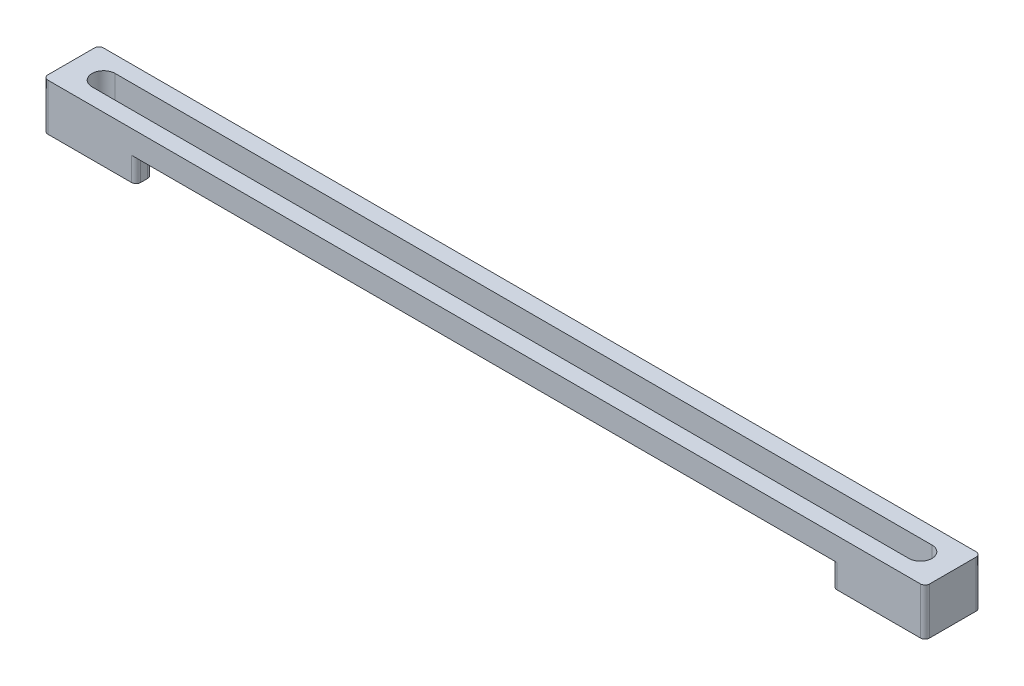
from build123d import *

# Parameters (mm, degrees)
ESQUISSE1_W        = 190
ESQUISSE1_H        = 12
BOSS_EXTRU_1_DEPTH = 2.5
BOSS_EXTRU_3_DEPTH = 5.1
CONG_1_R           = 1


with BuildPart() as part:
    # Esquisse1 → Boss.-Extru.1 (new body, symmetric)
    with BuildSketch(Plane(origin=(0, 0, 0), x_dir=(1, 0, 0), z_dir=(0, 1, 0))):
        Rectangle(ESQUISSE1_W, ESQUISSE1_H)
        with BuildLine():
            Line((-88, 2.5), (88, 2.5))
            ThreePointArc((88, 2.5), (90.5, 0), (88, -2.5))
            Line((88, -2.5), (-88, -2.5))
            ThreePointArc((-88, -2.5), (-90.5, 0), (-88, 2.5))
        make_face(mode=Mode.SUBTRACT)
    extrude(amount=BOSS_EXTRU_1_DEPTH, both=True)

    # Esquisse4 → Boss.-Extru.3 (add)
    with BuildSketch(Plane.XZ.offset(2.5)):
        with BuildLine():
            Line((-95, 6), (-75, 6))
            Line((-75, 6), (-75, 2.5))
            Line((-75, 2.5), (-88, 2.5))
            ThreePointArc((-88, 2.5), (-90.5, 0), (-88, -2.5))
            Line((-88, -2.5), (-75, -2.5))
            Line((-75, -2.5), (-75, -6))
            Line((-75, -6), (-95, -6))
            Line((-95, -6), (-95, 6))
        make_face()
    boss_extru_3 = extrude(amount=BOSS_EXTRU_3_DEPTH)

    # Symétrie2: Boss.-Extru.3 across plane
    add(boss_extru_3.mirror(Plane(origin=(0, 0, 0), x_dir=(0, 0, 1), z_dir=(1, 0, 0))))

    # Congé1
    cong_1_edges = [part.edges().sort_by_distance(p)[0] for p in [
        (-75, -5.05, -6),
        (-75, -5.05, -2.5),
        (-75, -5.05, 2.5),
        (-75, -5.05, 6),
        (75, -5.05, 6),
        (75, -5.05, 2.5),
        (75, -5.05, -2.5),
        (75, -5.05, -6),
        (95, -2.55, 6),
        (-95, -2.55, 6),
        (-95, -2.55, -6),
        (95, -2.55, -6),
    ]]
    fillet(cong_1_edges, radius=CONG_1_R)


solid = part.part
